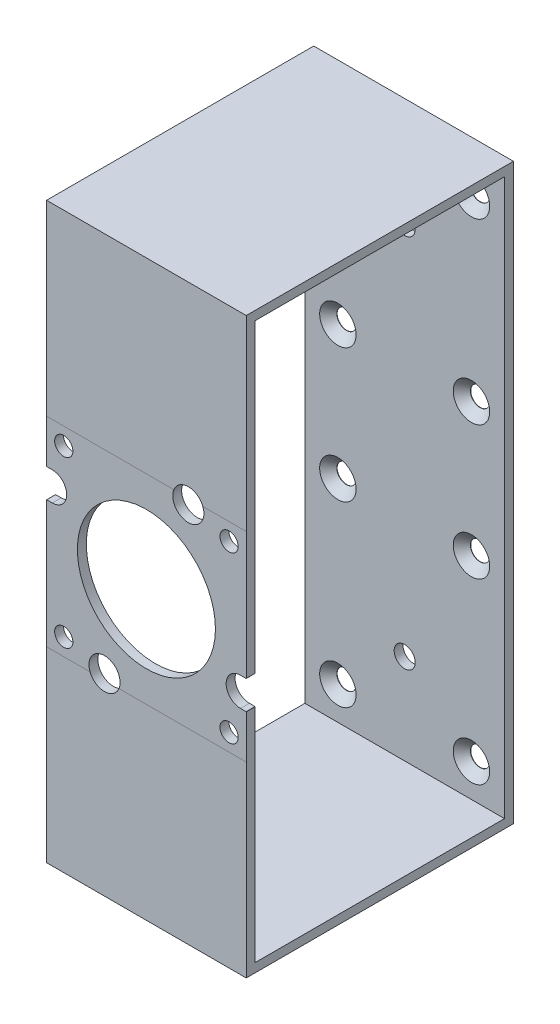
from build123d import *

# Parameters (mm, degrees)
BOSS_EXTRUDE1_DEPTH                            = 2.54
SKETCH2_R                                      = 2.6
CUT_EXTRUDE1_DEPTH                             = 3.5400001
CUT_EXTRUDE1_DEPTH_BACK                        = 1.0000001
BOSS_EXTRUDE2_DEPTH                            = 2.54
SKETCH5_R                                      = 19.685
CUT_EXTRUDE2_DEPTH                             = 2.54
SKETCH6_W                                      = 56.950712044
SKETCH6_H                                      = 76.2
BOSS_EXTRUDE3_DEPTH                            = 2.54
SKETCH7_W                                      = 56.950712044
SKETCH7_H                                      = 76.2
BOSS_EXTRUDE5_DEPTH                            = 2.54
SKETCH10_W                                     = 56.950712044
SKETCH10_H                                     = 2.54
SKETCH8_W                                      = 56.950712044
SKETCH8_H                                      = 2.54
CUT_EXTRUDE3_REACH                             = 78.2
SKETCH12_R                                     = 4.44110741
CSK_FOR_M5_FLAT_HEAD_MACHINE_SCREW1_AT_2_COUNT = 2
CSK_FOR_M5_FLAT_HEAD_MACHINE_SCREW1_AT_2_PITCH = 38.1
CSK_FOR_M5_FLAT_HEAD_MACHINE_SCREW1_AT_3_COUNT = 2
CSK_FOR_M5_FLAT_HEAD_MACHINE_SCREW1_AT_3_PITCH = 50.8
CSK_FOR_M5_FLAT_HEAD_MACHINE_SCREW1_AT_4_COUNT = 2
CSK_FOR_M5_FLAT_HEAD_MACHINE_SCREW1_AT_4_PITCH = 63.5
CSK_FOR_M5_FLAT_HEAD_MACHINE_SCREW1_AT_5_COUNT = 2
CSK_FOR_M5_FLAT_HEAD_MACHINE_SCREW1_AT_5_PITCH = 88.9
CSK_FOR_M5_FLAT_HEAD_MACHINE_SCREW1_AT_6_COUNT = 2
CSK_FOR_M5_FLAT_HEAD_MACHINE_SCREW1_AT_6_PITCH = 96.720318444
CSK_FOR_M5_FLAT_HEAD_MACHINE_SCREW1_AT_7_COUNT = 2
CSK_FOR_M5_FLAT_HEAD_MACHINE_SCREW1_AT_7_PITCH = 139.7
CSK_FOR_M5_FLAT_HEAD_MACHINE_SCREW1_AT_8_COUNT = 2
CSK_FOR_M5_FLAT_HEAD_MACHINE_SCREW1_AT_8_PITCH = 144.802278988
SKETCH26_R                                     = 3
CUT_EXTRUDE5_DEPTH                             = 10


with BuildPart() as part:
    # Sketch3 → Boss-Extrude1 (new body)
    with BuildSketch(Plane(origin=(0, 0, -4.819), x_dir=(-1, 0, 0), z_dir=(0, 0, -1))):
        with BuildLine():
            Line((28.440509101, 7.854930932), (26.839601475, 7.854930932))
            ThreePointArc((26.839601475, 7.854930932), (22.744771928, 11.949760479), (26.839601475, 16.044590025))
            Line((26.839601475, 16.044590025), (28.440509101, 16.044590025))
            add(Edge.make_bspline(
                [(28.440509101, 16.044590025), (28.459137134, 16.044109711), (28.475836336, 16.060808913), (28.475356022, 16.079436946)],
                knots=[2.356803478, 2.356803478, 2.356803478, 2.356803478, 3.926381829, 3.926381829, 3.926381829, 3.926381829], degree=3))
            Line((28.475356022, 16.079436946), (28.475356022, 25.845))
            ThreePointArc((28.475356022, 25.845), (27.70494258, 27.70494258), (25.845, 28.475356022))
            Line((25.845, 28.475356022), (-7.820084012, 28.475356022))
            add(Edge.make_bspline(
                [(-7.820084012, 28.475356022), (-7.838712044, 28.475836336), (-7.855411247, 28.459137134), (-7.854930932, 28.440509101)],
                knots=[-0.784789176, -0.784789176, -0.784789176, -0.784789176, 0.784789176, 0.784789176, 0.784789176, 0.784789176], degree=3))
            Line((-7.854930932, 28.440509101), (-7.854930932, 26.839601475))
            ThreePointArc((-7.854930932, 26.839601475), (-11.949760479, 22.744771928), (-16.044590025, 26.839601475))
            Line((-16.044590025, 26.839601475), (-16.044590025, 28.440509101))
            add(Edge.make_bspline(
                [(-16.044590025, 28.440509101), (-16.044109711, 28.459137134), (-16.060808913, 28.475836336), (-16.079436946, 28.475356022)],
                knots=[2.356803478, 2.356803478, 2.356803478, 2.356803478, 3.926381829, 3.926381829, 3.926381829, 3.926381829], degree=3))
            Line((-16.079436946, 28.475356022), (-25.845, 28.475356022))
            ThreePointArc((-25.845, 28.475356022), (-27.70494258, 27.70494258), (-28.475356022, 25.845))
            Line((-28.475356022, 25.845), (-28.475356022, -7.820084012))
            add(Edge.make_bspline(
                [(-28.475356022, -7.820084012), (-28.475836336, -7.838712044), (-28.459137134, -7.855411247), (-28.440509101, -7.854930932)],
                knots=[-0.784789176, -0.784789176, -0.784789176, -0.784789176, 0.784789176, 0.784789176, 0.784789176, 0.784789176], degree=3))
            Line((-28.440509101, -7.854930932), (-26.839601475, -7.854930932))
            ThreePointArc((-26.839601475, -7.854930932), (-22.744771928, -11.949760479), (-26.839601475, -16.044590025))
            Line((-26.839601475, -16.044590025), (-28.440509101, -16.044590025))
            add(Edge.make_bspline(
                [(-28.440509101, -16.044590025), (-28.459137134, -16.044109711), (-28.475836336, -16.060808913), (-28.475356022, -16.079436946)],
                knots=[2.356803478, 2.356803478, 2.356803478, 2.356803478, 3.926381829, 3.926381829, 3.926381829, 3.926381829], degree=3))
            Line((-28.475356022, -16.079436946), (-28.475356022, -25.845))
            ThreePointArc((-28.475356022, -25.845), (-27.70494258, -27.70494258), (-25.845, -28.475356022))
            Line((-25.845, -28.475356022), (7.820084012, -28.475356022))
            add(Edge.make_bspline(
                [(7.820084012, -28.475356022), (7.838712044, -28.475836336), (7.855411247, -28.459137134), (7.854930932, -28.440509101)],
                knots=[-0.784789176, -0.784789176, -0.784789176, -0.784789176, 0.784789176, 0.784789176, 0.784789176, 0.784789176], degree=3))
            Line((7.854930932, -28.440509101), (7.854930932, -26.839601475))
            ThreePointArc((7.854930932, -26.839601475), (11.949760479, -22.744771928), (16.044590025, -26.839601475))
            Line((16.044590025, -26.839601475), (16.044590025, -28.440509101))
            add(Edge.make_bspline(
                [(16.044590025, -28.440509101), (16.044109711, -28.459137134), (16.060808913, -28.475836336), (16.079436946, -28.475356022)],
                knots=[2.356803478, 2.356803478, 2.356803478, 2.356803478, 3.926381829, 3.926381829, 3.926381829, 3.926381829], degree=3))
            Line((16.079436946, -28.475356022), (25.845, -28.475356022))
            ThreePointArc((25.845, -28.475356022), (27.70494258, -27.70494258), (28.475356022, -25.845))
            Line((28.475356022, -25.845), (28.475356022, 7.820084012))
            add(Edge.make_bspline(
                [(28.475356022, 7.820084012), (28.475836336, 7.838712044), (28.459137134, 7.855411247), (28.440509101, 7.854930932)],
                knots=[-0.784789176, -0.784789176, -0.784789176, -0.784789176, 0.784789176, 0.784789176, 0.784789176, 0.784789176], degree=3))
        make_face()
    extrude(amount=BOSS_EXTRUDE1_DEPTH)

    # Sketch2 → Cut-Extrude1 (cut, two sides)
    with BuildSketch(Plane(origin=(0, 0, -4.819), x_dir=(-1, 0, 0), z_dir=(0, 0, -1))) as cut_extrude1_sk:
        with Locations((-23.573172318, -23.573172318)):
            Circle(SKETCH2_R)
        with Locations((-23.573172318, 23.573172318)):
            Circle(SKETCH2_R)
        with Locations((23.573172318, 23.573172318)):
            Circle(SKETCH2_R)
        with Locations((23.573172318, -23.573172318)):
            Circle(SKETCH2_R)
    extrude(amount=CUT_EXTRUDE1_DEPTH, mode=Mode.SUBTRACT)
    extrude(cut_extrude1_sk.sketch, amount=-CUT_EXTRUDE1_DEPTH_BACK, mode=Mode.SUBTRACT)

    # Sketch4 → Boss-Extrude2 (add)
    with BuildSketch(Plane.XY.offset(-4.819)):
        with BuildLine():
            Line((-28.475356022, 25.845), (-28.475356022, 79.275356022))
            Line((-28.475356022, 79.275356022), (28.475356022, 79.275356022))
            Line((28.475356022, 79.275356022), (28.475356022, 25.845))
            ThreePointArc((28.475356022, 25.845), (27.70494258, 27.70494258), (25.845, 28.475356022))
            Line((25.845, 28.475356022), (-25.845, 28.475356022))
            ThreePointArc((-25.845, 28.475356022), (-27.70494258, 27.70494258), (-28.475356022, 25.845))
        make_face()
        with BuildLine():
            Line((-28.475356022, -25.845), (-28.475356022, -79.275356022))
            Line((-28.475356022, -79.275356022), (28.475356022, -79.275356022))
            Line((28.475356022, -79.275356022), (28.475356022, -25.845))
            ThreePointArc((28.475356022, -25.845), (27.70494258, -27.70494258), (25.845, -28.475356022))
            Line((25.845, -28.475356022), (-25.845, -28.475356022))
            ThreePointArc((-25.845, -28.475356022), (-27.70494258, -27.70494258), (-28.475356022, -25.845))
        make_face()
    extrude(amount=-BOSS_EXTRUDE2_DEPTH)

    # Sketch5 → Cut-Extrude2 (cut)
    with BuildSketch(Plane.XY.offset(-4.819)):
        Circle(SKETCH5_R)
    extrude(amount=-CUT_EXTRUDE2_DEPTH, mode=Mode.SUBTRACT)

    # Sketch6 → Boss-Extrude3 (add)
    with BuildSketch(Plane(origin=(0, 79.275356022, 0), x_dir=(1, 0, 0), z_dir=(0, 1, 0))):
        with Locations((0, 42.919)):
            Rectangle(SKETCH6_W, SKETCH6_H)
    extrude(amount=BOSS_EXTRUDE3_DEPTH)

    # Sketch7 → Boss-Extrude5 (add)
    with BuildSketch(Plane.XZ.offset(79.275356022)):
        with Locations((0, -42.919)):
            Rectangle(SKETCH7_W, SKETCH7_H)
    extrude(amount=BOSS_EXTRUDE5_DEPTH)

    # Sketch10 → Loft1 section 0
    with BuildSketch(Plane.XZ.offset(-79.275356022)):
        with Locations((0, -79.749)):
            Rectangle(SKETCH10_W, SKETCH10_H)
    # Sketch8 → Loft1 section 1
    with BuildSketch(Plane(origin=(0, -79.275356022, 0), x_dir=(1, 0, 0), z_dir=(0, 1, 0))):
        with Locations((0, 79.749)):
            Rectangle(SKETCH8_W, SKETCH8_H)
    loft()

    # Sketch12 → Cut-Extrude3 (cut, up to next)
    with BuildSketch(Plane.XY.offset(-4.819), mode=Mode.PRIVATE) as cut_extrude3_sk1:
        with Locations((-11.949760479, -26.839601475)):
            Circle(SKETCH12_R)
    cut_extrude3_tool1 = extrude(cut_extrude3_sk1.sketch, amount=-CUT_EXTRUDE3_REACH, mode=Mode.PRIVATE) & part.part
    add(cut_extrude3_tool1.solids().sort_by_distance((-11.94976, -26.839601, -4.819))[0], mode=Mode.SUBTRACT)
    # Sketch12 → Cut-Extrude3 (cut, up to next)
    with BuildSketch(Plane.XY.offset(-4.819), mode=Mode.PRIVATE) as cut_extrude3_sk2:
        with Locations((11.949760479, 26.839601475)):
            Circle(SKETCH12_R)
    cut_extrude3_tool2 = extrude(cut_extrude3_sk2.sketch, amount=-CUT_EXTRUDE3_REACH, mode=Mode.PRIVATE) & part.part
    add(cut_extrude3_tool2.solids().sort_by_distance((11.94976, 26.839601, -4.819))[0], mode=Mode.SUBTRACT)

    # Sketch20 → CSK for M5 Flat Head Machine Screw1 (revolve, cut)
    with BuildSketch(Plane(origin=(-19.05, 69.85, -78.479), x_dir=(0, -1, 0), z_dir=(1, 0, 0))):
        Polygon((0, 0), (0, 2.54), (2.75, 2.54), (2.75, 2.45), (5.2, 0), align=None)
    csk_for_m5_flat_head_machine_screw1 = revolve(axis=Axis((-19.05, 69.85, -72.129), (0, 0, -1)), mode=Mode.SUBTRACT)

    # CSK for M5 Flat Head Machine Screw1 at 2: CSK for M5 Flat Head Machine Screw1 ×2
    with Locations(*[(i * CSK_FOR_M5_FLAT_HEAD_MACHINE_SCREW1_AT_2_PITCH, 0, 0) for i in range(1, CSK_FOR_M5_FLAT_HEAD_MACHINE_SCREW1_AT_2_COUNT)]):
        add(csk_for_m5_flat_head_machine_screw1, mode=Mode.SUBTRACT)

    # CSK for M5 Flat Head Machine Screw1 at 3: CSK for M5 Flat Head Machine Screw1 ×2
    with Locations(*[(0, -i * CSK_FOR_M5_FLAT_HEAD_MACHINE_SCREW1_AT_3_PITCH, 0) for i in range(1, CSK_FOR_M5_FLAT_HEAD_MACHINE_SCREW1_AT_3_COUNT)]):
        add(csk_for_m5_flat_head_machine_screw1, mode=Mode.SUBTRACT)

    # CSK for M5 Flat Head Machine Screw1 at 4: CSK for M5 Flat Head Machine Screw1 ×2
    with Locations(*[Vector(0.6, -0.8, 0) * (i * CSK_FOR_M5_FLAT_HEAD_MACHINE_SCREW1_AT_4_PITCH) for i in range(1, CSK_FOR_M5_FLAT_HEAD_MACHINE_SCREW1_AT_4_COUNT)]):
        add(csk_for_m5_flat_head_machine_screw1, mode=Mode.SUBTRACT)

    # CSK for M5 Flat Head Machine Screw1 at 5: CSK for M5 Flat Head Machine Screw1 ×2
    with Locations(*[(0, -i * CSK_FOR_M5_FLAT_HEAD_MACHINE_SCREW1_AT_5_PITCH, 0) for i in range(1, CSK_FOR_M5_FLAT_HEAD_MACHINE_SCREW1_AT_5_COUNT)]):
        add(csk_for_m5_flat_head_machine_screw1, mode=Mode.SUBTRACT)

    # CSK for M5 Flat Head Machine Screw1 at 6: CSK for M5 Flat Head Machine Screw1 ×2
    with Locations(*[Vector(0.393919299, -0.91914503, 0) * (i * CSK_FOR_M5_FLAT_HEAD_MACHINE_SCREW1_AT_6_PITCH) for i in range(1, CSK_FOR_M5_FLAT_HEAD_MACHINE_SCREW1_AT_6_COUNT)]):
        add(csk_for_m5_flat_head_machine_screw1, mode=Mode.SUBTRACT)

    # CSK for M5 Flat Head Machine Screw1 at 7: CSK for M5 Flat Head Machine Screw1 ×2
    with Locations(*[(0, -i * CSK_FOR_M5_FLAT_HEAD_MACHINE_SCREW1_AT_7_PITCH, 0) for i in range(1, CSK_FOR_M5_FLAT_HEAD_MACHINE_SCREW1_AT_7_COUNT)]):
        add(csk_for_m5_flat_head_machine_screw1, mode=Mode.SUBTRACT)

    # CSK for M5 Flat Head Machine Screw1 at 8: CSK for M5 Flat Head Machine Screw1 ×2
    with Locations(*[Vector(0.263117406, -0.964763821, 0) * (i * CSK_FOR_M5_FLAT_HEAD_MACHINE_SCREW1_AT_8_PITCH) for i in range(1, CSK_FOR_M5_FLAT_HEAD_MACHINE_SCREW1_AT_8_COUNT)]):
        add(csk_for_m5_flat_head_machine_screw1, mode=Mode.SUBTRACT)

    # Sketch26 → Cut-Extrude5 (cut)
    with BuildSketch(Plane.XY.offset(-78.479)):
        with Locations((0, 53.5)):
            Circle(SKETCH26_R)
        with Locations((0, -53.5)):
            Circle(SKETCH26_R)
    extrude(amount=-CUT_EXTRUDE5_DEPTH, mode=Mode.SUBTRACT)


solid = part.part
